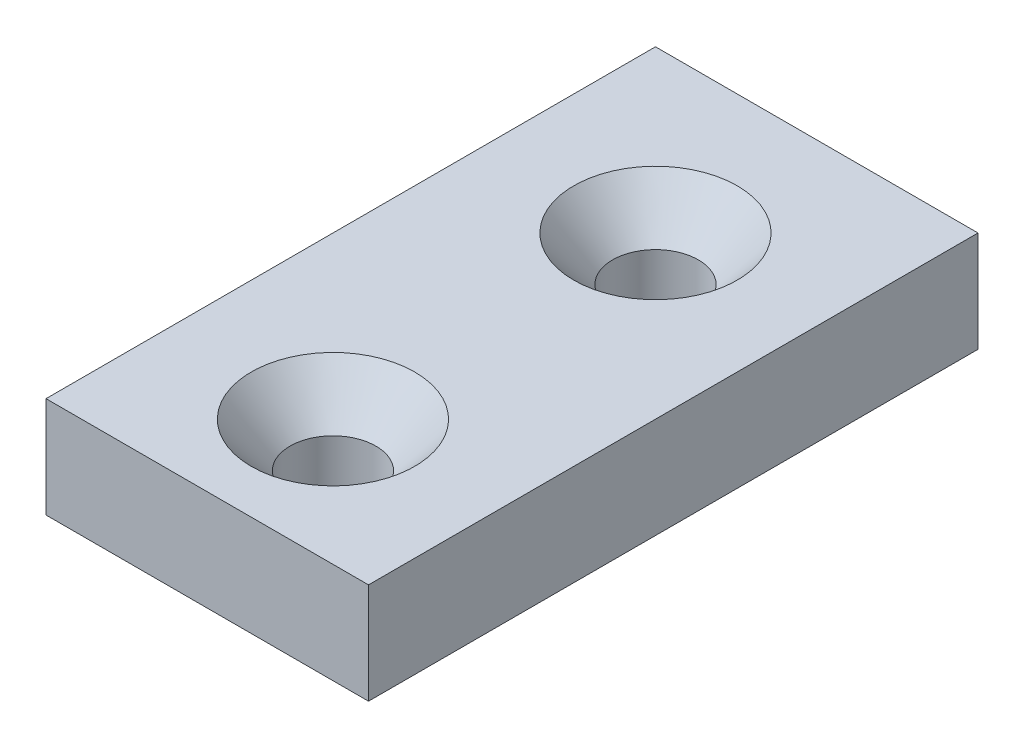
from build123d import *

# Parameters (mm, degrees)
SKETCH3_W                                        = 25.4
SKETCH3_H                                        = 7.9375
BOSS_EXTRUDE1_DEPTH                              = 24
CSK_FOR_1_4_FLAT_HEAD_MACHINE_SCREW1_D           = 6.7564
CSK_FOR_1_4_FLAT_HEAD_MACHINE_SCREW1_CSINK_D     = 12.8778
CSK_FOR_1_4_FLAT_HEAD_MACHINE_SCREW1_CSINK_ANGLE = 82


with BuildPart() as part:
    # Sketch3 → Boss-Extrude1 (new body, symmetric)
    with BuildSketch(Plane.XY):
        Rectangle(SKETCH3_W, SKETCH3_H)
    extrude(amount=BOSS_EXTRUDE1_DEPTH, both=True)

    # CSK for 1/4 Flat Head Machine Screw1 (through all)
    with Locations(Plane(origin=(0, 3.96875, 0), x_dir=(-1, 0, 0), z_dir=(0, 1, 0))):
        with Locations((0, 14.1), (0, -11.3)):
            CounterSinkHole(CSK_FOR_1_4_FLAT_HEAD_MACHINE_SCREW1_D / 2, CSK_FOR_1_4_FLAT_HEAD_MACHINE_SCREW1_CSINK_D / 2, counter_sink_angle=CSK_FOR_1_4_FLAT_HEAD_MACHINE_SCREW1_CSINK_ANGLE)


solid = part.part
